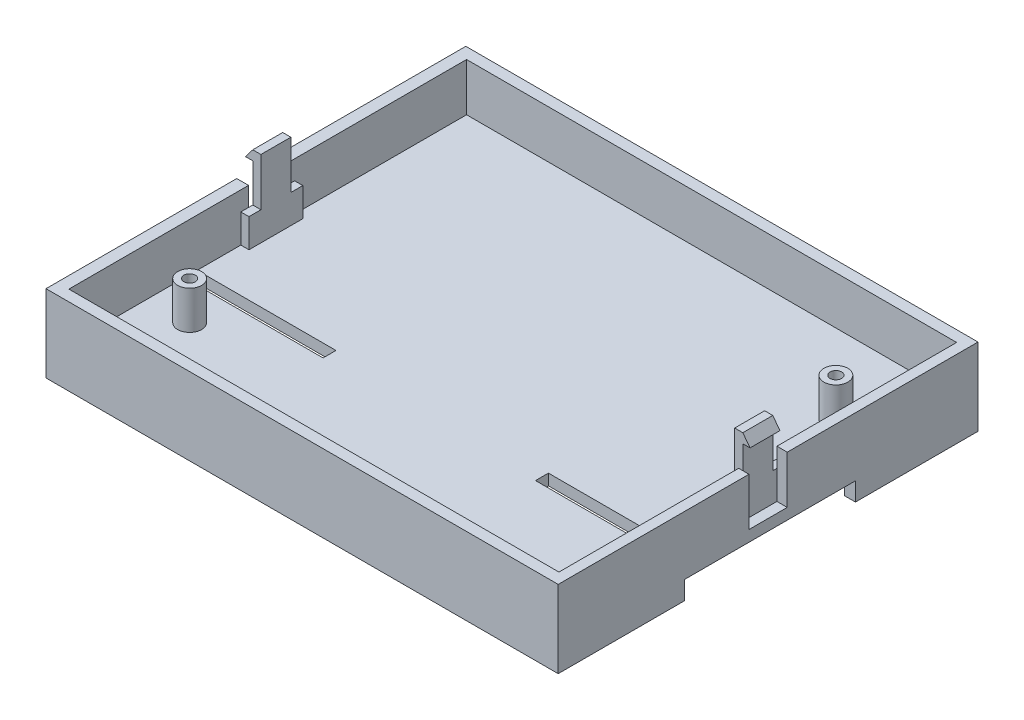
from build123d import *

# Parameters (mm, degrees)
SKETCH1_W           = 107
SKETCH1_H           = 87.7
BOSS_EXTRUDE1_DEPTH = 2.31
BOSS_EXTRUDE2_DEPTH = 10
SKETCH3_R           = 2.5
SKETCH3_R_2         = 1.2
BOSS_EXTRUDE3_DEPTH = 8
BOSS_EXTRUDE4_DEPTH = 3.85
SKETCH5_W           = 28
SKETCH5_H           = 2.7
CUT_EXTRUDE1_DEPTH  = 3.85
CUT_EXTRUDE2_DEPTH  = 107
SKETCH7_W           = 1.7
SKETCH7_H           = 11.25
BOSS_EXTRUDE5_DEPTH = 16
SKETCH8_W           = 2.5
SKETCH8_H           = 10
CUT_EXTRUDE3_DEPTH  = 102.38
BOSS_EXTRUDE6_DEPTH = 6.25
BOSS_EXTRUDE7_DEPTH = 6.25


with BuildPart() as part:
    # Sketch1 → Boss-Extrude1 (new body)
    with BuildSketch(Plane(origin=(0, 0, 0), x_dir=(1, 0, 0), z_dir=(0, 1, 0))):
        with Locations((53.5, 43.85)):
            Rectangle(SKETCH1_W, SKETCH1_H)
    extrude(amount=BOSS_EXTRUDE1_DEPTH)

    # Sketch2 → Boss-Extrude2 (add)
    with BuildSketch(Plane(origin=(0, 2.31, 0), x_dir=(1, 0, 0), z_dir=(0, 1, 0))):
        Polygon((0, 47.85), (2.466911691, 47.85), (2.466911691, 85.39), (104.846911691, 85.39), (104.846911691, 47.85), (107, 47.85), (107, 87.7), (0, 87.7), align=None)
        Polygon((0, 0), (107, 0), (107, 39.85), (104.846911691, 39.85), (104.846911691, 2.31), (2.466911691, 2.31), (2.466911691, 39.85), (0, 39.85), align=None)
    extrude(amount=BOSS_EXTRUDE2_DEPTH)

    # Sketch3 → Boss-Extrude3 (add)
    with BuildSketch(Plane(origin=(0, 2.31, 0), x_dir=(1, 0, 0), z_dir=(0, 1, 0))):
        with Locations((11.156911691, 18.85)):
            Circle(SKETCH3_R)
        with Locations((11.156911691, 18.85)):
            Circle(SKETCH3_R_2, mode=Mode.SUBTRACT)
        with Locations((96.156911691, 68.85)):
            Circle(SKETCH3_R)
        with Locations((96.156911691, 68.85)):
            Circle(SKETCH3_R_2, mode=Mode.SUBTRACT)
    extrude(amount=BOSS_EXTRUDE3_DEPTH)

    # Sketch4 → Boss-Extrude4 (add)
    with BuildSketch(Plane(origin=(0, 0, 0), x_dir=(-1, 0, 0), z_dir=(0, -1, 0))):
        Polygon((0, 0), (0, 26.416), (-4.0894, 26.416), (-4.0894, 29.1084), (-29.9974, 29.1084), (-29.9974, 24.6112), (-2.31, 24.6112), (-2.31, 2.31), (-104.69, 2.31), (-104.69, 24.6112), (-77.0026, 24.6112), (-77.0026, 29.1084), (-102.9106, 29.1084), (-102.9106, 26.416), (-107, 26.416), (-107, 0), align=None)
        Polygon((0, 62.1), (0, 87.7), (-47.32, 87.7), (-47.32, 62.1), (-9.31, 62.1), (-9.31, 64.41), (-43.3322, 64.41), (-43.3322, 85.39), (-2.31, 85.39), (-2.31, 62.1), align=None)
        Polygon((-59.68, 87.7), (-107, 87.7), (-107, 62.1), (-104.69, 62.1), (-104.69, 85.39), (-63.6678, 85.39), (-63.6678, 64.41), (-97.69, 64.41), (-97.69, 62.1), (-59.68, 62.1), align=None)
    extrude(amount=BOSS_EXTRUDE4_DEPTH)

    # Sketch5 → Cut-Extrude1 (cut)
    with BuildSketch(Plane(origin=(0, 2.31, 0), x_dir=(1, 0, 0), z_dir=(0, 1, 0))):
        with Locations((17.466911691, 27.76)):
            Rectangle(SKETCH5_W, SKETCH5_H)
        with Locations((89.846911691, 27.76)):
            Rectangle(SKETCH5_W, SKETCH5_H)
    extrude(amount=-CUT_EXTRUDE1_DEPTH, mode=Mode.SUBTRACT)

    # Sketch6 → Cut-Extrude2 (cut)
    with BuildSketch(Plane(origin=(102.9106, 0, 0), x_dir=(0, 0, -1), z_dir=(1, 0, 0))):
        Polygon((29.1084, -3.85), (26.416, -1.54), (29.1084, -1.54), align=None)
    extrude(amount=-CUT_EXTRUDE2_DEPTH, mode=Mode.SUBTRACT)

    # Sketch7 → Boss-Extrude5 (add)
    with BuildSketch(Plane(origin=(0, 2.31, 0), x_dir=(1, 0, 0), z_dir=(0, 1, 0))):
        with Locations((3.316911691, 43.855)):
            Rectangle(SKETCH7_W, SKETCH7_H)
        with Locations((103.996911691, 43.855)):
            Rectangle(SKETCH7_W, SKETCH7_H)
    extrude(amount=BOSS_EXTRUDE5_DEPTH)

    # Sketch8 → Cut-Extrude3 (cut)
    with BuildSketch(Plane(origin=(104.846911691, 0, 0), x_dir=(0, 0, -1), z_dir=(1, 0, 0))):
        with Locations((39.48, 13.31)):
            Rectangle(SKETCH8_W, SKETCH8_H)
        with Locations((48.23, 13.31)):
            Rectangle(SKETCH8_W, SKETCH8_H)
    extrude(amount=-CUT_EXTRUDE3_DEPTH, mode=Mode.SUBTRACT)

    # Sketch9 → Boss-Extrude6 (add)
    with BuildSketch(Plane.XY.offset(-40.73)):
        Polygon((104.846911691, 18.31), (106.346911691, 16.31), (104.846911691, 16.31), align=None)
    extrude(amount=-BOSS_EXTRUDE6_DEPTH)

    # Sketch10 → Boss-Extrude7 (add)
    with BuildSketch(Plane.XY.offset(-40.73)):
        Polygon((0.966911691, 16.31), (2.466911691, 16.31), (2.466911691, 18.31), align=None)
    extrude(amount=-BOSS_EXTRUDE7_DEPTH)


solid = part.part
